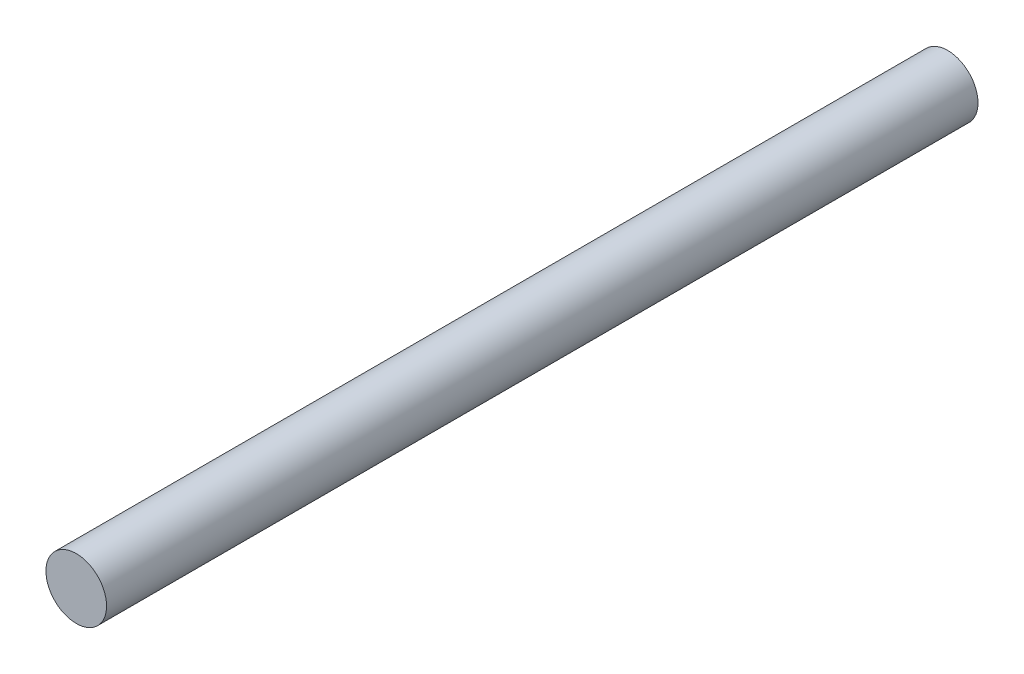
from build123d import *

# Parameters (mm, degrees)
SKETCH1_R           = 4
BOSS_EXTRUDE1_DEPTH = 115


with BuildPart() as part:
    # Sketch1 → Boss-Extrude1 (new body)
    with BuildSketch(Plane.XY):
        Circle(SKETCH1_R)
    extrude(amount=BOSS_EXTRUDE1_DEPTH)


solid = part.part
